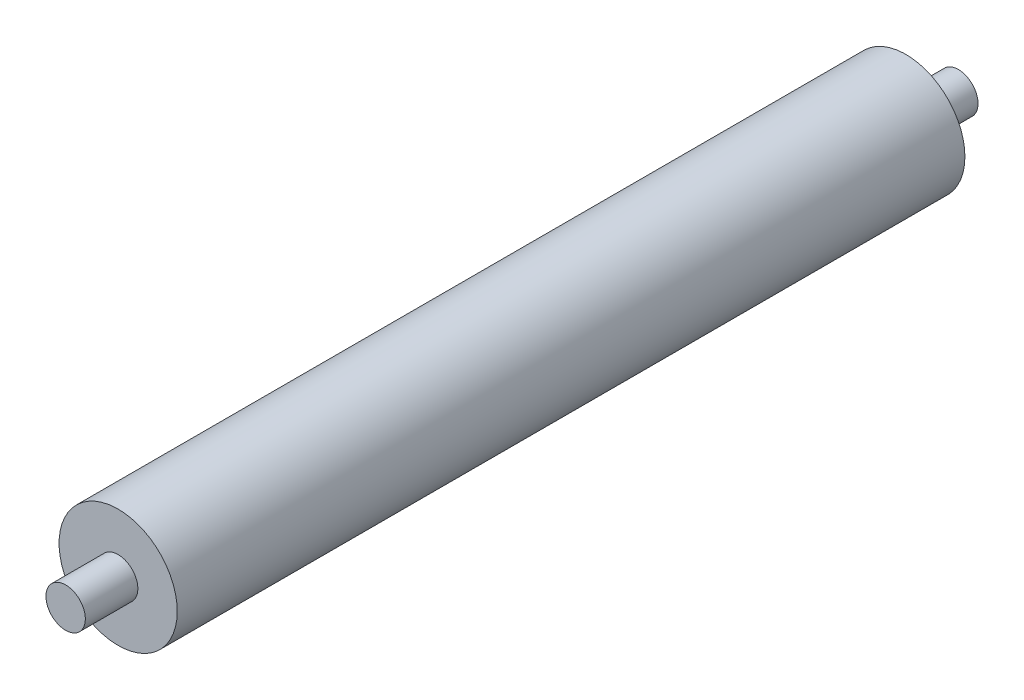
from build123d import *

# Parameters (mm, degrees)
SKETCH1_R           = 22.5
BOSS_EXTRUDE1_DEPTH = 300
SKETCH2_R           = 7.5
BOSS_EXTRUDE2_DEPTH = 20
SKETCH3_R           = 7.5
BOSS_EXTRUDE3_DEPTH = 20


with BuildPart() as part:
    # Sketch1 → Boss-Extrude1 (new body)
    with BuildSketch(Plane.XY):
        Circle(SKETCH1_R)
    extrude(amount=BOSS_EXTRUDE1_DEPTH)

    # Sketch2 → Boss-Extrude2 (add)
    with BuildSketch(Plane.XY.offset(300)):
        Circle(SKETCH2_R)
    extrude(amount=BOSS_EXTRUDE2_DEPTH)

    # Sketch3 → Boss-Extrude3 (add)
    with BuildSketch(Plane(origin=(0, 0, 0), x_dir=(-1, 0, 0), z_dir=(0, 0, -1))):
        Circle(SKETCH3_R)
    extrude(amount=BOSS_EXTRUDE3_DEPTH)


solid = part.part
